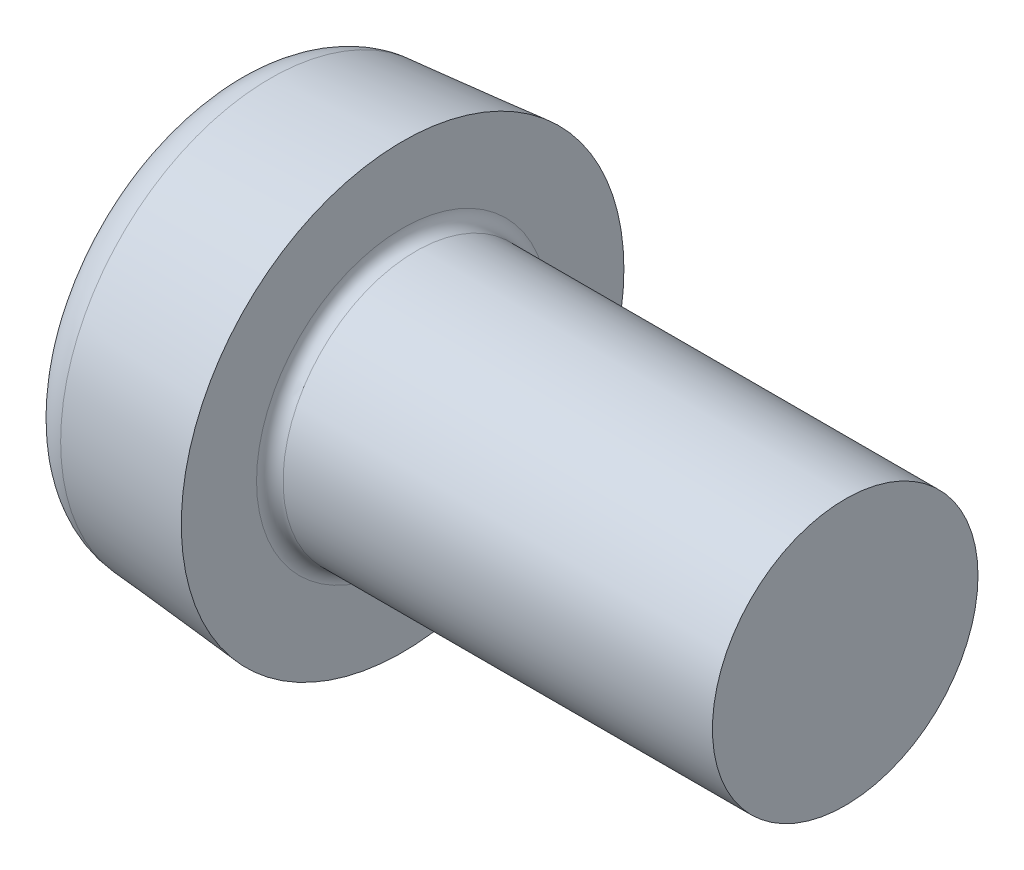
from build123d import *

# Parameters (mm, degrees)
CROSSRECESS_DEPTH = 3.9
FILLET5_R         = 0.3
HEADFILLET_R      = 1
DRAFT1_ANGLE      = 20


with BuildPart() as part:
    # Sketch1 → Base (revolve)
    with BuildSketch(Plane.XY):
        with BuildLine():
            Line((13.9, 3), (5.9, 3))
            Line((5.9, 3), (4.2, 3))
            ThreePointArc((4.2, 3), (3.987867966, 3.087867966), (3.9, 3.3))
            Line((3.9, 3.3), (3.9, 5))
            Line((3.9, 5), (0, 4.658794212))
            Line((0, 4.658794212), (0, 0))
            Line((0, 0), (13.9, 0))
            Line((13.9, 0), (13.9, 3))
        make_face()
    revolve(axis=Axis((4.515812911, 0, 0), (-1, 0, 0)))

    # Sketch6 → CrossRecess (cut)
    with BuildSketch(Plane(origin=(0, 0, 0), x_dir=(0, 0, -1), z_dir=(1, 0, 0))):
        Polygon((0.62, 0.62), (0.62, 3.1), (-0.62, 3.1), (-0.62, 0.62), (-3.1, 0.62), (-3.1, -0.62), (-0.62, -0.62), (-0.62, -3.1), (0.62, -3.1), (0.62, -0.62), (3.1, -0.62), (3.1, 0.62), align=None)
    extrude(amount=CROSSRECESS_DEPTH, mode=Mode.SUBTRACT)

    # Fillet5
    fillet5_edges = [part.edges().sort_by_distance(p)[0] for p in [
        (1.95, 0.62, 0.62),
        (1.95, -0.62, 0.62),
        (1.95, -0.62, -0.62),
        (1.95, 0.62, -0.62),
    ]]
    fillet(fillet5_edges, radius=FILLET5_R)

    # HeadFillet
    headfillet_edges = [part.edges().sort_by_distance(p)[0] for p in [
        (0, -4.658794212, 0),
    ]]
    fillet(headfillet_edges, radius=HEADFILLET_R)

    # Draft1
    draft1_faces = [part.faces().sort_by_distance(p)[0] for p in [
        (1.95, 0, 3.1),
        (1.95, -3.1, 0),
        (1.95, 0, -3.1),
        (1.95, 3.1, 0),
    ]]
    draft(draft1_faces, Plane(origin=(0, 0, 0), x_dir=(0, 0, -1), z_dir=(-1, 0, 0)), DRAFT1_ANGLE)


solid = part.part
